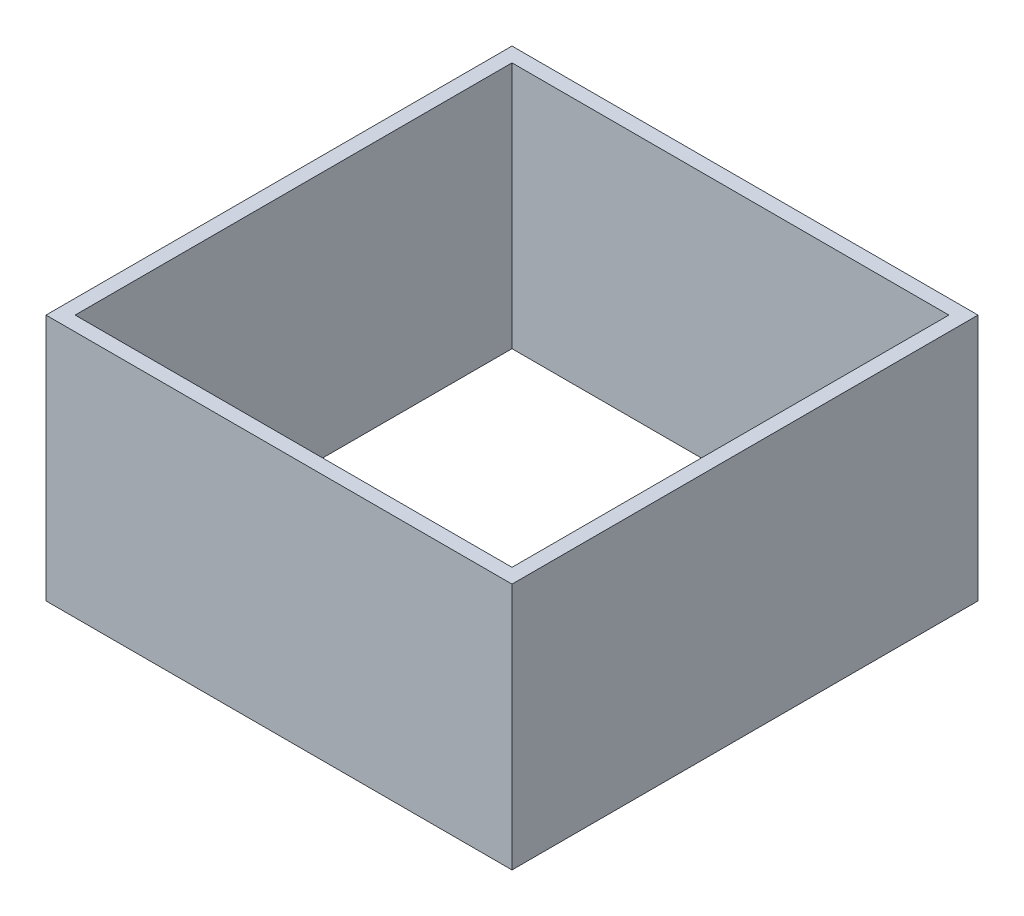
from build123d import *

# Parameters (mm, degrees)
SKETCH2_W           = 101.6
SKETCH2_H           = 101.6
SKETCH2_W_2         = 95.25
SKETCH2_H_2         = 95.25
BOSS_EXTRUDE1_DEPTH = 53.975


with BuildPart() as part:
    # Sketch2 → Boss-Extrude1 (new body)
    with BuildSketch(Plane(origin=(0, 0, 0), x_dir=(1, 0, 0), z_dir=(0, 1, 0))):
        Rectangle(SKETCH2_W, SKETCH2_H)
        Rectangle(SKETCH2_W_2, SKETCH2_H_2, mode=Mode.SUBTRACT)
    extrude(amount=BOSS_EXTRUDE1_DEPTH)


solid = part.part
